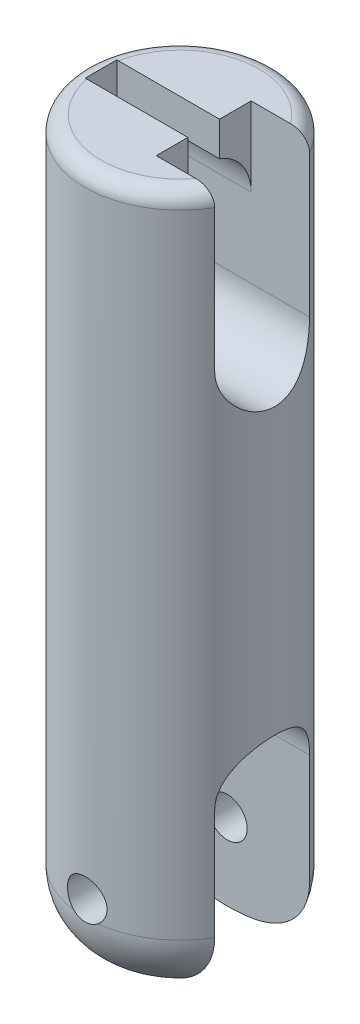
from build123d import *

# Parameters (mm, degrees)
SKETCH1_R               = 6
BOSS_EXTRUDE1_DEPTH     = 45
FILLET1_R               = 1
FILLET2_R               = 4
SKETCH2_R               = 1.25
CUT_EXTRUDE1_DEPTH      = 7
CUT_EXTRUDE1_DEPTH_BACK = 7
CUT_EXTRUDE2_DEPTH      = 7.0000001
CUT_EXTRUDE2_DEPTH_BACK = 7.0000001
CUT_EXTRUDE3_DEPTH      = 7.0000001
CUT_EXTRUDE3_DEPTH_BACK = 5
CUT_EXTRUDE4_DEPTH      = 7.0000001
CUT_EXTRUDE4_DEPTH_BACK = 5
CUT_EXTRUDE5_DEPTH      = 10


with BuildPart() as part:
    # Sketch1 → Boss-Extrude1 (new body)
    with BuildSketch(Plane(origin=(0, 0, 0), x_dir=(1, 0, 0), z_dir=(0, 1, 0))):
        Circle(SKETCH1_R)
    extrude(amount=BOSS_EXTRUDE1_DEPTH)

    # Fillet1
    fillet1_edges = [part.edges().sort_by_distance(p)[0] for p in [
        (-6, 45, 0),
    ]]
    fillet(fillet1_edges, radius=FILLET1_R)

    # Fillet2
    fillet2_edges = [part.edges().sort_by_distance(p)[0] for p in [
        (-6, 0, 0),
    ]]
    fillet(fillet2_edges, radius=FILLET2_R)

    # Sketch2 → Cut-Extrude1 (cut, two sides)
    with BuildSketch(Plane.XY) as cut_extrude1_sk:
        with Locations((0, 5)):
            Circle(SKETCH2_R)
    extrude(amount=CUT_EXTRUDE1_DEPTH, mode=Mode.SUBTRACT)
    extrude(cut_extrude1_sk.sketch, amount=-CUT_EXTRUDE1_DEPTH_BACK, mode=Mode.SUBTRACT)

    # Sketch3 → Cut-Extrude2 (cut, two sides)
    with BuildSketch(Plane(origin=(0, 0, 0), x_dir=(0, 0, -1), z_dir=(1, 0, 0))) as cut_extrude2_sk:
        with BuildLine():
            Line((-3, 0), (-3, 11))
            ThreePointArc((-3, 11), (0, 14), (3, 11))
            Line((3, 11), (3, 0))
            ThreePointArc((3, 0), (0, -3), (-3, 0))
        make_face()
    extrude(amount=CUT_EXTRUDE2_DEPTH, mode=Mode.SUBTRACT)
    extrude(cut_extrude2_sk.sketch, amount=-CUT_EXTRUDE2_DEPTH_BACK, mode=Mode.SUBTRACT)

    # Sketch4 → Cut-Extrude3 (cut, two sides)
    with BuildSketch(Plane(origin=(0, 0, 0), x_dir=(0, 0, -1), z_dir=(1, 0, 0))) as cut_extrude3_sk:
        with BuildLine():
            Line((-3, 35), (-3, 40))
            ThreePointArc((-3, 40), (0, 43), (3, 40))
            Line((3, 40), (3, 35))
            ThreePointArc((3, 35), (0, 32), (-3, 35))
        make_face()
    extrude(amount=CUT_EXTRUDE3_DEPTH, mode=Mode.SUBTRACT)
    extrude(cut_extrude3_sk.sketch, amount=-CUT_EXTRUDE3_DEPTH_BACK, mode=Mode.SUBTRACT)

    # Sketch5 → Cut-Extrude4 (cut, two sides)
    with BuildSketch(Plane(origin=(0, 0, 0), x_dir=(0, 0, -1), z_dir=(1, 0, 0))) as cut_extrude4_sk:
        with BuildLine():
            Line((1, 45), (1, 40))
            ThreePointArc((1, 40), (0, 39), (-1, 40))
            Line((-1, 40), (-1, 45))
            ThreePointArc((-1, 45), (0, 46), (1, 45))
        make_face()
    extrude(amount=CUT_EXTRUDE4_DEPTH, mode=Mode.SUBTRACT)
    extrude(cut_extrude4_sk.sketch, amount=-CUT_EXTRUDE4_DEPTH_BACK, mode=Mode.SUBTRACT)

    # Sketch6 → Cut-Extrude5 (cut)
    with BuildSketch(Plane(origin=(1.5, 0, 0), x_dir=(0, 0, -1), z_dir=(1, 0, 0))):
        with BuildLine():
            Line((3, 45.000000046), (3, 36.772414369))
            ThreePointArc((3, 36.772414369), (0, 33.772414369), (-3, 36.772414369))
            Line((-3, 36.772414369), (-3, 45.000000046))
            ThreePointArc((-3, 45.000000046), (0, 48.000000046), (3, 45.000000046))
        make_face()
    extrude(amount=CUT_EXTRUDE5_DEPTH, mode=Mode.SUBTRACT)


solid = part.part
